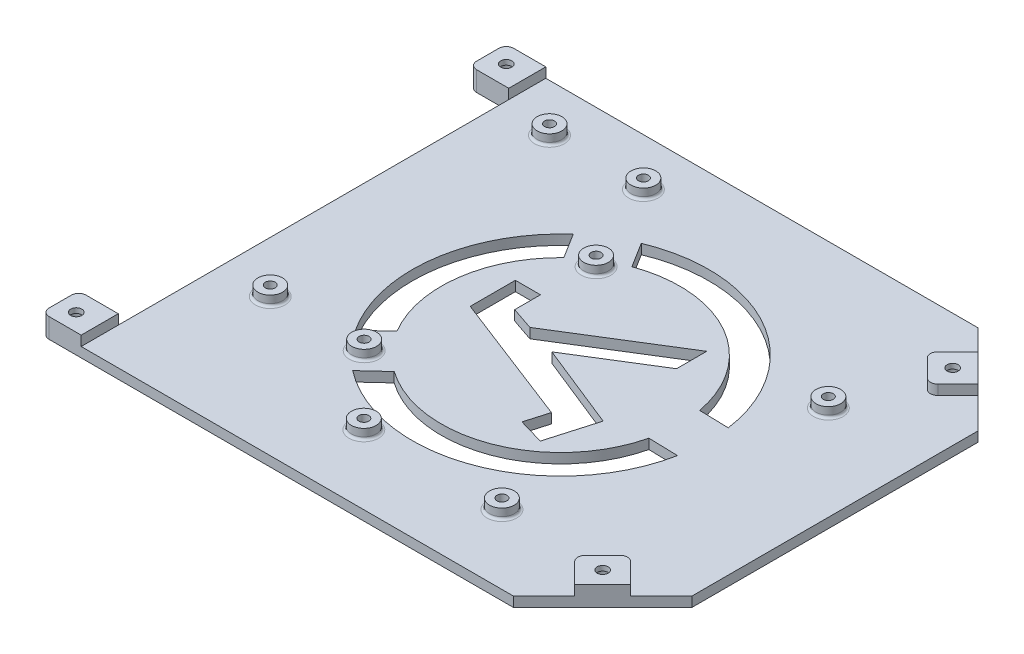
from build123d import *

# Parameters (mm, degrees)
BOSS_EXTRUDE1_DEPTH     = 2
SKETCH2_W               = 8
SKETCH2_H               = 7.5
BOSS_EXTRUDE2_DEPTH     = 2
SKETCH3_R               = 1.125
CUT_EXTRUDE1_DEPTH      = 5
SKETCH4_R               = 2.5
BOSS_EXTRUDE3_DEPTH     = 2
SKETCH5_R               = 1
CUT_EXTRUDE2_DEPTH      = 2.5
FILLET1_R               = 0.5
CUT_EXTRUDE6_DEPTH      = 5
FILLET2_R               = 1.5
FILLET3_R               = 1.5
CUT_EXTRUDE7_DEPTH      = 3
CUT_EXTRUDE7_DEPTH_BACK = 3
SKETCH8_R               = 2
CUT_EXTRUDE8_DEPTH      = 1
CUT_EXTRUDE8_DEPTH_BACK = 3


with BuildPart() as part:
    # Sketch1 → Boss-Extrude1 (new body)
    with BuildSketch(Plane(origin=(0, 0, 0), x_dir=(1, 0, 0), z_dir=(0, 1, 0))):
        Polygon((61.25, 30), (44.25, 47), (-44.25, 47), (-52.25, 47), (-52.25, 39.5), (-44.25, 39.5), (-44.25, -39.5), (-52.25, -39.5), (-52.25, -47), (-44.25, -47), (44.25, -47), (61.25, -30), align=None)
    extrude(amount=BOSS_EXTRUDE1_DEPTH)

    # Sketch2 → Boss-Extrude2 (add)
    with BuildSketch(Plane(origin=(0, 2, 0), x_dir=(1, 0, 0), z_dir=(0, 1, 0))):
        with Locations((-48.25, 43.25)):
            Rectangle(SKETCH2_W, SKETCH2_H)
        with Locations((-48.25, -43.25)):
            Rectangle(SKETCH2_W, SKETCH2_H)
        Polygon((55.578427125, -35.671572875), (49.921572875, -41.328427125), (44.264718626, -35.671572875), (49.921572875, -30.014718626), align=None)
        Polygon((49.921572875, 41.328427125), (55.578427125, 35.671572875), (49.921572875, 30.014718626), (44.264718626, 35.671572875), align=None)
    extrude(amount=BOSS_EXTRUDE2_DEPTH)

    # Sketch3 → Cut-Extrude1 (cut, through all)
    with BuildSketch(Plane(origin=(0, 4, 0), x_dir=(1, 0, 0), z_dir=(0, 1, 0))):
        with Locations((49.65, 35.405)):
            Circle(SKETCH3_R)
        with Locations((-48.75, -43.5)):
            Circle(SKETCH3_R)
        with Locations((-48.75, 43.5)):
            Circle(SKETCH3_R)
        with Locations((49.65, -35.405)):
            Circle(SKETCH3_R)
    extrude(amount=-CUT_EXTRUDE1_DEPTH, mode=Mode.SUBTRACT)

    # Sketch4 → Boss-Extrude3 (add)
    with BuildSketch(Plane(origin=(0, 2, 0), x_dir=(1, 0, 0), z_dir=(0, 1, 0))):
        with Locations((-33.9, 37.4)):
            Circle(SKETCH4_R)
        with Locations((-14.9, 37.4)):
            Circle(SKETCH4_R)
        with Locations((-33.9, -19.1)):
            Circle(SKETCH4_R)
        with Locations((-14.9, -19.1)):
            Circle(SKETCH4_R)
        with Locations((-6.160101909, 19.084114492)):
            Circle(SKETCH4_R)
        with Locations((42.099898091, 17.814114492)):
            Circle(SKETCH4_R)
        with Locations((-1.080101909, -32.985885508)):
            Circle(SKETCH4_R)
        with Locations((26.859898091, -32.985885508)):
            Circle(SKETCH4_R)
    extrude(amount=BOSS_EXTRUDE3_DEPTH)

    # Sketch5 → Cut-Extrude2 (cut)
    with BuildSketch(Plane(origin=(0, 4, 0), x_dir=(1, 0, 0), z_dir=(0, 1, 0))):
        with Locations((-33.9, 37.4)):
            Circle(SKETCH5_R)
        with Locations((-14.9, 37.4)):
            Circle(SKETCH5_R)
        with Locations((-6.160101909, 19.084114492)):
            Circle(SKETCH5_R)
        with Locations((42.099898091, 17.814114492)):
            Circle(SKETCH5_R)
        with Locations((26.859898091, -32.985885508)):
            Circle(SKETCH5_R)
        with Locations((-1.080101909, -32.985885508)):
            Circle(SKETCH5_R)
        with Locations((-14.9, -19.1)):
            Circle(SKETCH5_R)
        with Locations((-33.9, -19.1)):
            Circle(SKETCH5_R)
    extrude(amount=-CUT_EXTRUDE2_DEPTH, mode=Mode.SUBTRACT)

    # Fillet1
    fillet1_edges = [part.edges().sort_by_distance(p)[0] for p in [
        (-36.4, 2, -37.4),
        (-8.660101909, 2, -19.084114492),
        (-17.4, 2, 19.1),
        (-36.4, 2, 19.1),
        (-17.4, 2, -37.4),
        (24.359898091, 2, 32.985885508),
        (-3.580101909, 2, 32.985885508),
        (39.599898091, 2, -17.814114492),
    ]]
    fillet(fillet1_edges, radius=FILLET1_R)

    # Sketch6 → Cut-Extrude6 (cut, through all)
    with BuildSketch(Plane.XZ):
        Polygon((-11.934093721, 0.6084348), (-11.934093721, -8.526035833), (-6.854645098, -8.526035833), (-6.854645098, -3.318533883), (-2.202040897, -1.739209522), (19.865815724, -15.44091547), (19.865815724, -9.337040235), (4.302175748, 0.326264277), (21.615877855, 7.267207784), (18.756020227, 17.127313934), (13.547804779, 15.616705991), (14.887513366, 10.997710715), align=None)
        with BuildLine():
            Line((-12.570519348, 23.756232252), (-8.199804463, 19.713585555))
            ThreePointArc((-8.199804463, 19.713585555), (14.25380266, 22.603270567), (29.234576835, 5.63002228))
            Line((29.234576835, 5.63002228), (35.186113899, 5.789231255))
            ThreePointArc((35.186113899, 5.789231255), (16.313730012, 28.078596978), (-12.570519348, 23.756232252))
        make_face()
        with BuildLine():
            Line((-19.360699682, 16.415016342), (-14.989984797, 12.372369645))
            ThreePointArc((-14.989984797, 12.372369645), (-18.18602874, -3.2076515), (-11.000682227, -17.396469324))
            Line((-11.000682227, -17.396469324), (-14.152793546, -22.447245022))
            ThreePointArc((-14.152793546, -22.447245022), (-23.984197193, -3.984660248), (-19.360699682, 16.415016342))
        make_face()
        with BuildLine():
            Line((-2.517210782, -22.690873185), (-5.669322101, -27.741648883))
            ThreePointArc((-5.669322101, -27.741648883), (20.65119785, -26.037555619), (35.453527237, -4.207192611))
            Line((35.453527237, -4.207192611), (29.501990173, -4.366401586))
            ThreePointArc((29.501990173, -4.366401586), (17.74546427, -20.960232273), (-2.517210782, -22.690873185))
        make_face()
    extrude(amount=-CUT_EXTRUDE6_DEPTH, mode=Mode.SUBTRACT)

    # Fillet2
    fillet2_edges = [part.edges().sort_by_distance(p)[0] for p in [
        (-52.25, 2, 47),
        (-52.25, 2, 39.5),
        (-52.25, 2, -39.5),
        (-52.25, 2, -47),
    ]]
    fillet(fillet2_edges, radius=FILLET2_R)

    # Fillet3
    fillet3_edges = [part.edges().sort_by_distance(p)[0] for p in [
        (44.264718626, 3, -35.671572875),
        (49.921572875, 3, -30.014718626),
        (49.921572875, 3, 30.014718626),
        (44.264718626, 3, 35.671572875),
    ]]
    fillet(fillet3_edges, radius=FILLET3_R)

    # Sketch7 → Cut-Extrude7 (cut, two sides)
    with BuildSketch(Plane(origin=(0, 2, 0), x_dir=(1, 0, 0), z_dir=(0, 1, 0))) as cut_extrude7_sk:
        Polygon((41.903432703, 49.346567297), (63.963988577, 27.286011423), (63.433658491, 26.755681338), (41.373102617, 48.816237211), align=None)
        Polygon((41.986991098, -49.263008902), (64.162392896, -27.087607104), (63.632062811, -26.557277018), (41.456661012, -48.732678816), align=None)
    extrude(amount=CUT_EXTRUDE7_DEPTH, mode=Mode.SUBTRACT)
    extrude(cut_extrude7_sk.sketch, amount=-CUT_EXTRUDE7_DEPTH_BACK, mode=Mode.SUBTRACT)

    # Sketch8 → Cut-Extrude8 (cut, two sides)
    with BuildSketch(Plane.XZ) as cut_extrude8_sk:
        with Locations((-48.75, 43.5)):
            Circle(SKETCH8_R)
        with Locations((49.65, 35.405)):
            Circle(SKETCH8_R)
        with Locations((49.65, -35.405)):
            Circle(SKETCH8_R)
        with Locations((-48.75, -43.5)):
            Circle(SKETCH8_R)
    extrude(amount=CUT_EXTRUDE8_DEPTH, mode=Mode.SUBTRACT)
    extrude(cut_extrude8_sk.sketch, amount=-CUT_EXTRUDE8_DEPTH_BACK, mode=Mode.SUBTRACT)


solid = part.part
